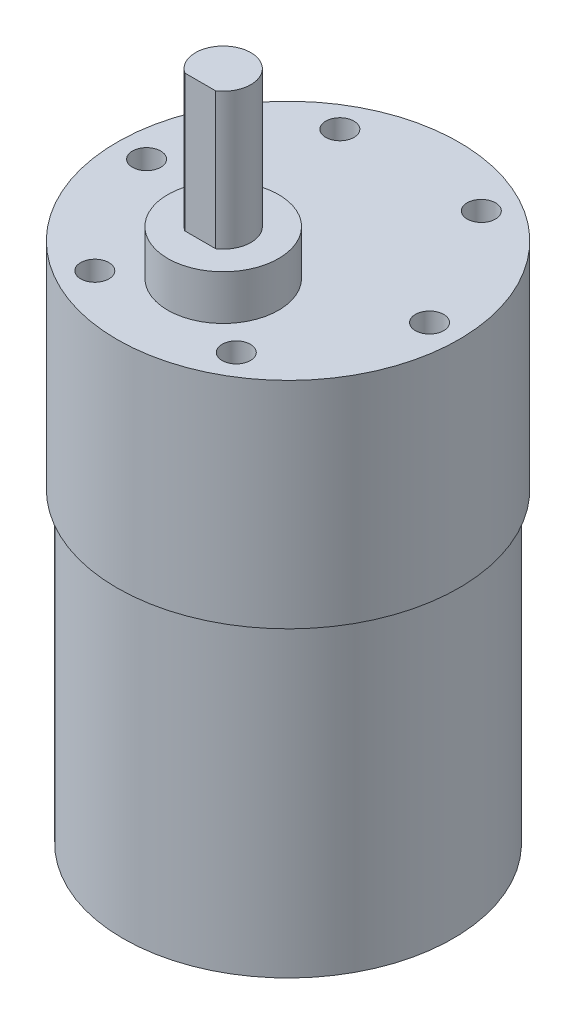
from build123d import *

# Parameters (mm, degrees)
SKETCH1_R           = 17.78
BOSS_EXTRUDE1_DEPTH = 33.02
SKETCH2_R           = 18.415
BOSS_EXTRUDE2_DEPTH = 23.1775
SKETCH3_R           = 1.524
CUT_EXTRUDE1_DEPTH  = 12.7
SKETCH4_R           = 5.969
BOSS_EXTRUDE3_DEPTH = 4.826
BOSS_EXTRUDE4_DEPTH = 14.732


with BuildPart() as part:
    # Sketch1 → Boss-Extrude1 (new body)
    with BuildSketch(Plane(origin=(0, 0, 0), x_dir=(1, 0, 0), z_dir=(0, 1, 0))):
        Circle(SKETCH1_R)
    extrude(amount=BOSS_EXTRUDE1_DEPTH)

    # Sketch2 → Boss-Extrude2 (add)
    with BuildSketch(Plane(origin=(0, 33.02, 0), x_dir=(1, 0, 0), z_dir=(0, 1, 0))):
        Circle(SKETCH2_R)
    extrude(amount=BOSS_EXTRUDE2_DEPTH)

    # Sketch3 → Cut-Extrude1 (cut)
    with BuildSketch(Plane(origin=(0, 56.1975, 0), x_dir=(1, 0, 0), z_dir=(0, 1, 0))):
        with Locations((15.24, 0)):
            Circle(SKETCH3_R)
        with Locations((7.62, -13.198227154)):
            Circle(SKETCH3_R)
        with Locations((-7.62, -13.198227154)):
            Circle(SKETCH3_R)
        with Locations((-15.24, 0)):
            Circle(SKETCH3_R)
        with Locations((-7.62, 13.198227154)):
            Circle(SKETCH3_R)
        with Locations((7.62, 13.198227154)):
            Circle(SKETCH3_R)
    extrude(amount=-CUT_EXTRUDE1_DEPTH, mode=Mode.SUBTRACT)

    # Sketch4 → Boss-Extrude3 (add)
    with BuildSketch(Plane(origin=(0, 56.1975, 0), x_dir=(1, 0, 0), z_dir=(0, 1, 0))):
        with Locations((0, -6.985)):
            Circle(SKETCH4_R)
    extrude(amount=BOSS_EXTRUDE3_DEPTH)

    # Sketch5 → Boss-Extrude4 (add)
    with BuildSketch(Plane(origin=(0, 61.0235, 0), x_dir=(1, 0, 0), z_dir=(0, 1, 0))):
        with BuildLine():
            Line((1.665589385, -9.4615), (-1.665589385, -9.4615))
            ThreePointArc((-1.665589385, -9.4615), (0, -4.0005), (1.665589385, -9.4615))
        make_face()
    extrude(amount=BOSS_EXTRUDE4_DEPTH)


solid = part.part
